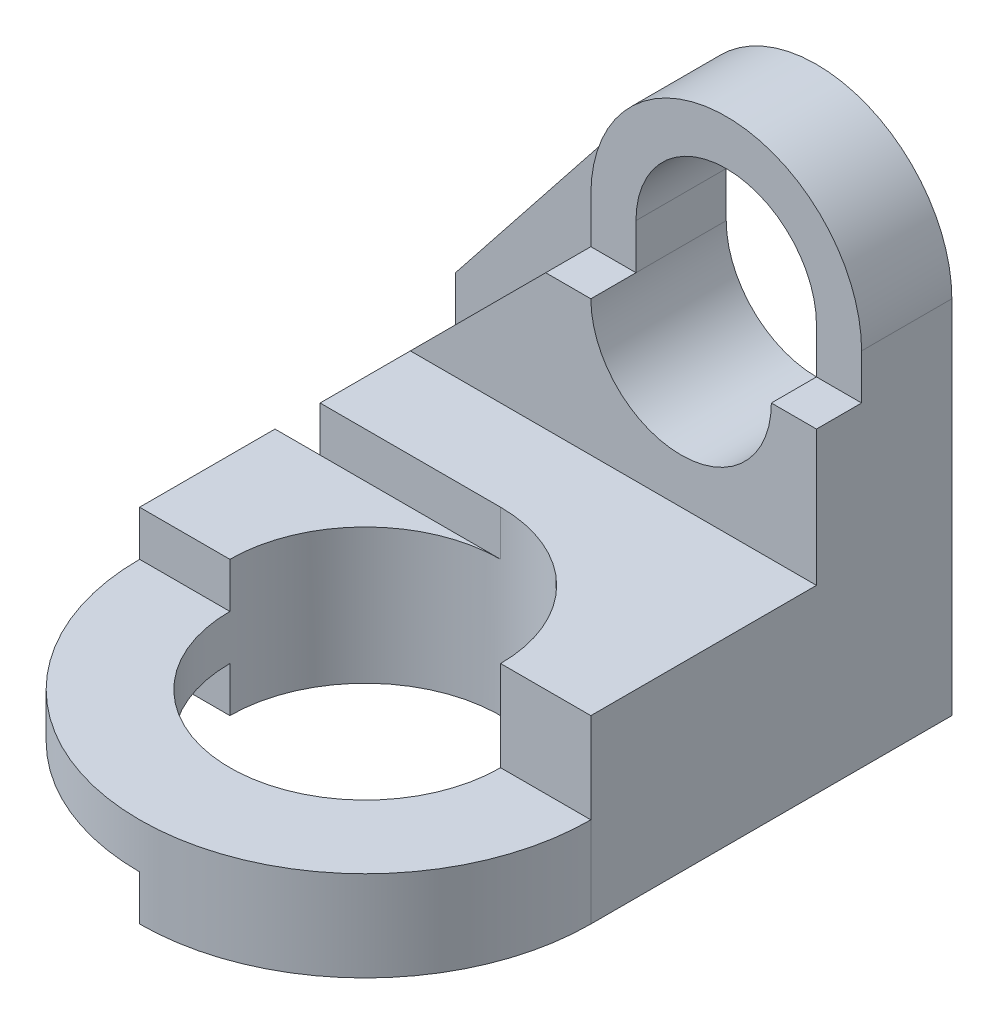
from build123d import *

# Parameters (mm, degrees)
BOSS_EXTRUDE1_DEPTH = 1
BOSS_EXTRUDE3_DEPTH = 2
SKETCH5_W           = 6.323405325
SKETCH5_H           = 4.405706714
CUT_EXTRUDE2_DEPTH  = 1
SKETCH6_W           = 9
SKETCH6_H           = 4
BOSS_EXTRUDE4_DEPTH = 2
SKETCH7_W           = 10
SKETCH7_H           = 3
BOSS_EXTRUDE5_DEPTH = 8
SKETCH8_R           = 3
CUT_EXTRUDE3_DEPTH  = 8
CUT_EXTRUDE4_DEPTH  = 1
CUT_EXTRUDE5_DEPTH  = 1
BOSS_EXTRUDE6_DEPTH = 1


with BuildPart() as part:
    # Sketch2 → Boss-Extrude1 (new body)
    with BuildSketch(Plane.XY):
        with BuildLine():
            Line((0, 0), (0, 4))
            Line((0, 4), (4.649234196, 9.863840158))
            ThreePointArc((4.649234196, 9.863840158), (7.986839041, 10.833045836), (10, 8))
            Line((10, 8), (10, 0))
            Line((10, 0), (0, 0))
        make_face()
        with BuildLine():
            Line((9, 8), (9, 7))
            ThreePointArc((9, 7), (7, 5), (5, 7))
            Line((5, 7), (5, 8))
            ThreePointArc((5, 8), (7, 10), (9, 8))
        make_face(mode=Mode.SUBTRACT)
    extrude(amount=BOSS_EXTRUDE1_DEPTH)

    # Sketch3 → Boss-Extrude3 (add)
    with BuildSketch(Plane.XY.offset(1)):
        with BuildLine():
            Line((1, 4), (1, 0))
            Line((1, 0), (10, 0))
            Line((10, 0), (10, 8))
            ThreePointArc((10, 8), (7, 11), (4, 8))
            Line((4, 8), (4, 7))
            Line((4, 7), (1, 4))
        make_face()
        with BuildLine():
            Line((5, 7), (5, 8))
            ThreePointArc((5, 8), (7, 10), (9, 8))
            Line((9, 8), (9, 7))
            ThreePointArc((9, 7), (7, 5), (5, 7))
        make_face(mode=Mode.SUBTRACT)
    extrude(amount=BOSS_EXTRUDE3_DEPTH)

    # Sketch5 → Cut-Extrude2 (cut)
    with BuildSketch(Plane.XY.offset(3)):
        with Locations((7.161702663, 9.202853357)):
            Rectangle(SKETCH5_W, SKETCH5_H)
    extrude(amount=-CUT_EXTRUDE2_DEPTH, mode=Mode.SUBTRACT)

    # Sketch6 → Boss-Extrude4 (add)
    with BuildSketch(Plane.XY.offset(3)):
        with Locations((5.5, 2)):
            Rectangle(SKETCH6_W, SKETCH6_H)
    extrude(amount=BOSS_EXTRUDE4_DEPTH)

    # Sketch7 → Boss-Extrude5 (add)
    with BuildSketch(Plane.XY.offset(5)):
        with Locations((5, 1.5)):
            Rectangle(SKETCH7_W, SKETCH7_H)
    extrude(amount=BOSS_EXTRUDE5_DEPTH)

    # Sketch8 → Cut-Extrude3 (cut)
    with BuildSketch(Plane(origin=(0, 4, 0), x_dir=(1, 0, 0), z_dir=(0, 1, 0))):
        with BuildLine():
            Line((10, -16.316770955), (10, -8))
            ThreePointArc((10, -8), (5, -13), (0, -8))
            Line((0, -8), (0, -16.316770955))
            Line((0, -16.316770955), (10, -16.316770955))
        make_face()
        with Locations((5, -8)):
            Circle(SKETCH8_R)
    extrude(amount=-CUT_EXTRUDE3_DEPTH, mode=Mode.SUBTRACT)

    # Sketch9 → Cut-Extrude4 (cut)
    with BuildSketch(Plane.XZ):
        with BuildLine():
            Line((5, 11), (5, 13))
            ThreePointArc((5, 13), (1.464466094, 11.535533906), (0, 8))
            Line((0, 8), (2, 8))
            ThreePointArc((2, 8), (2.878679656, 10.121320344), (5, 11))
        make_face()
    extrude(amount=-CUT_EXTRUDE4_DEPTH, mode=Mode.SUBTRACT)

    # Sketch10 → Cut-Extrude5 (cut)
    with BuildSketch(Plane(origin=(0, 3, 0), x_dir=(1, 0, 0), z_dir=(0, 1, 0))):
        with BuildLine():
            Line((0, -8), (2, -8))
            ThreePointArc((2, -8), (5, -11), (8, -8))
            Line((8, -8), (10, -8))
            ThreePointArc((10, -8), (5, -13), (0, -8))
        make_face()
    extrude(amount=-CUT_EXTRUDE5_DEPTH, mode=Mode.SUBTRACT)

    # Sketch11 → Boss-Extrude6 (add)
    with BuildSketch(Plane(origin=(0, 3, 0), x_dir=(1, 0, 0), z_dir=(0, 1, 0))):
        with BuildLine():
            Line((8, -8), (10, -8))
            Line((10, -8), (10, -5))
            Line((10, -5), (5, -5))
            ThreePointArc((5, -5), (7.121320344, -5.878679656), (8, -8))
        make_face()
    extrude(amount=BOSS_EXTRUDE6_DEPTH)


solid = part.part
